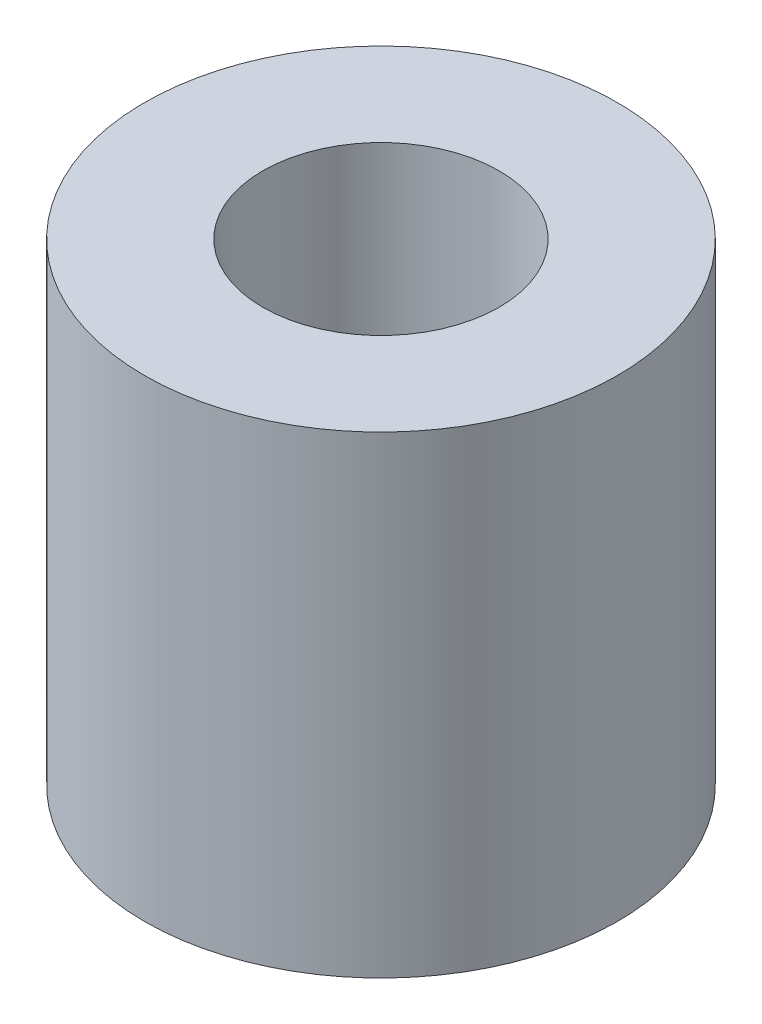
from build123d import *

# Parameters (mm, degrees)
SKETCH_1_R      = 6
SKETCH_1_R_2    = 3
EXTRUDE_1_DEPTH = 12


with BuildPart() as part:
    # 스케치1 → 보스-돌출1 (new body)
    with BuildSketch(Plane(origin=(0, 0, 0), x_dir=(1, 0, 0), z_dir=(0, 1, 0))):
        Circle(SKETCH_1_R)
        Circle(SKETCH_1_R_2, mode=Mode.SUBTRACT)
    extrude(amount=EXTRUDE_1_DEPTH)


solid = part.part
